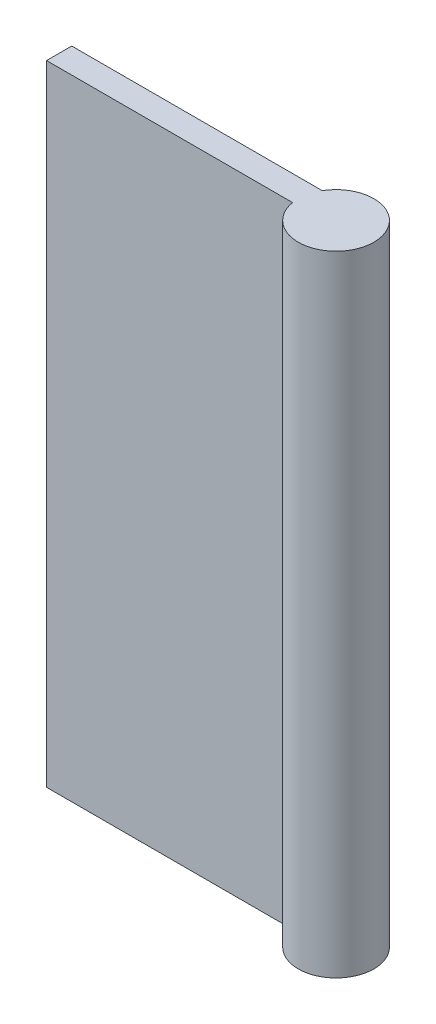
from build123d import *

# Parameters (mm, degrees)
SKETCH1_W           = 20
SKETCH1_H           = 50
BOSS_EXTRUDE1_DEPTH = 2
SKETCH2_R           = 3
BOSS_EXTRUDE2_DEPTH = 50


with BuildPart() as part:
    # Sketch1 → Boss-Extrude1 (new body)
    with BuildSketch(Plane.XY):
        Rectangle(SKETCH1_W, SKETCH1_H)
    extrude(amount=BOSS_EXTRUDE1_DEPTH)

    # Sketch2 → Boss-Extrude2 (add)
    with BuildSketch(Plane(origin=(0, 25, 0), x_dir=(1, 0, 0), z_dir=(0, 1, 0))):
        with Locations((12.5, -1.5)):
            Circle(SKETCH2_R)
    extrude(amount=-BOSS_EXTRUDE2_DEPTH)


solid = part.part
